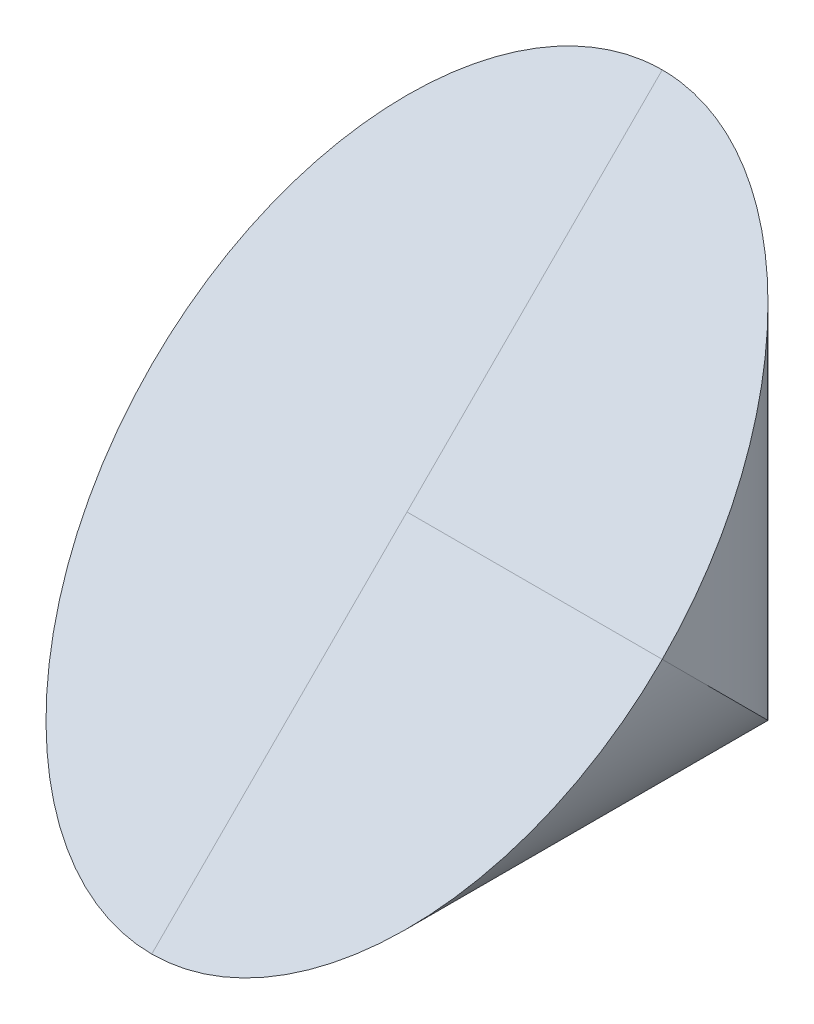
from build123d import *

# Parameters (mm, degrees)
SKETCH1_R               = 29.999999999999996
BOSS_EXTRUDE1_DEPTH     = 60
CUT_EXTRUDE2_DEPTH      = 60
CUT_EXTRUDE2_DEPTH_BACK = 60
CUT_EXTRUDE6_DEPTH      = 60
CUT_EXTRUDE6_DEPTH_BACK = 60
CUT_EXTRUDE7_DEPTH      = 0.0001
BOSS_EXTRUDE2_DEPTH     = 0.0001


with BuildPart() as part:
    # Sketch1 → Boss-Extrude1 (new body)
    with BuildSketch(Plane.XY):
        Circle(SKETCH1_R)
    extrude(amount=BOSS_EXTRUDE1_DEPTH)

    # Sketch2 → Cut-Extrude2 (cut, two sides: drawn at the far end of the back side and taken through both)
    with BuildSketch(Plane(origin=(0, 0, 0), x_dir=(1, 0, 0), z_dir=(0, 1, 0)).offset(-CUT_EXTRUDE2_DEPTH_BACK)):
        with BuildLine():
            Line((-7.1054e-13, 0), (-30, 0))
            Line((-30, 0), (-30, -30.00000000000002))
            ThreePointArc((-30, -29.999999999999996), (-21.213203435596675, -8.786796564403826), (-7.1093e-13, 0))
        make_face()
        with BuildLine():
            Line((30, 0), (-7.1054e-13, 0))
            ThreePointArc((-7.1093e-13, 0), (21.213203435596174, -8.786796564403325), (30, -30))
            Line((30, -30), (30, 0))
        make_face()
        with BuildLine():
            ThreePointArc((2.2327e-12, -60), (-21.213203435595638, -51.21320343559721), (-30, -29.999999999999996))
            Line((-30, -30.00000000000002), (-30, -60))
            Line((-30, -60), (2.2311e-12, -60))
        make_face()
        with BuildLine():
            Line((30, -60), (30, -30))
            ThreePointArc((30, -30.000000000000007), (21.21320343559721, -51.21320343559564), (2.2327e-12, -60))
            Line((2.2311e-12, -60), (30, -60))
        make_face()
    extrude(amount=CUT_EXTRUDE2_DEPTH + CUT_EXTRUDE2_DEPTH_BACK, mode=Mode.SUBTRACT)

    # Sketch7 → Cut-Extrude6 (cut, two sides: drawn at the far end of the back side and taken through both)
    with BuildSketch(Plane(origin=(0, 0, 0), x_dir=(0, 0, -1), z_dir=(1, 0, 0)).offset(-CUT_EXTRUDE6_DEPTH_BACK)):
        Polygon((0, 30), (-60, -30), (-60, 30), align=None)
    extrude(amount=CUT_EXTRUDE6_DEPTH + CUT_EXTRUDE6_DEPTH_BACK, mode=Mode.SUBTRACT)

    # Sketch8 → Cut-Extrude7 (cut)
    with BuildSketch(Plane(origin=(0, 15.000000000000005, 15.000000000000004), x_dir=(1, 0, 0), z_dir=(0, 0.7071067811865477, 0.7071067811865475))):
        with BuildLine():
            Line((2.22e-15, 21.21320343559642), (1.0474e-13, -21.213203435596412))
            Line((1.0474e-13, -21.213203435596412), (29.999999999999996, -21.213203435596427))
            add(Edge.make_bspline(
                [(30, -21.21320343559644), (30.000000000000018, 21.213203435596398), (1.677e-14, 21.21320343559642)],
                knots=[4.71238898038469, 4.71238898038469, 4.71238898038469, 6.283185307179586, 6.283185307179586, 6.283185307179586], degree=2, weights=[1, 0.7071067811865476, 1]))
        make_face()
    extrude(amount=-CUT_EXTRUDE7_DEPTH, mode=Mode.SUBTRACT)

    # Sketch9 → Boss-Extrude2 (add)
    with BuildSketch(Plane(origin=(0, 15.000000000000005, 15.000000000000004), x_dir=(1, 0, 0), z_dir=(0, 0.7071067811865477, 0.7071067811865475))):
        with BuildLine():
            Line((29.99999999995833, -21.213203435596427), (1.0408e-13, -21.213203435596416))
            Line((1.0408e-13, -21.213203435596416), (1.9602e-13, -63.639610306789265))
            add(Edge.make_bspline(
                [(-1.309e-14, -63.63961030678927), (29.999999999999982, -63.63961030678929), (30, -21.21320343559644)],
                knots=[3.141592653589793, 3.141592653589793, 3.141592653589793, 4.71238898038469, 4.71238898038469, 4.71238898038469], degree=2, weights=[1, 0.7071067811865476, 1]))
        make_face()
    extrude(amount=BOSS_EXTRUDE2_DEPTH)


solid = part.part
